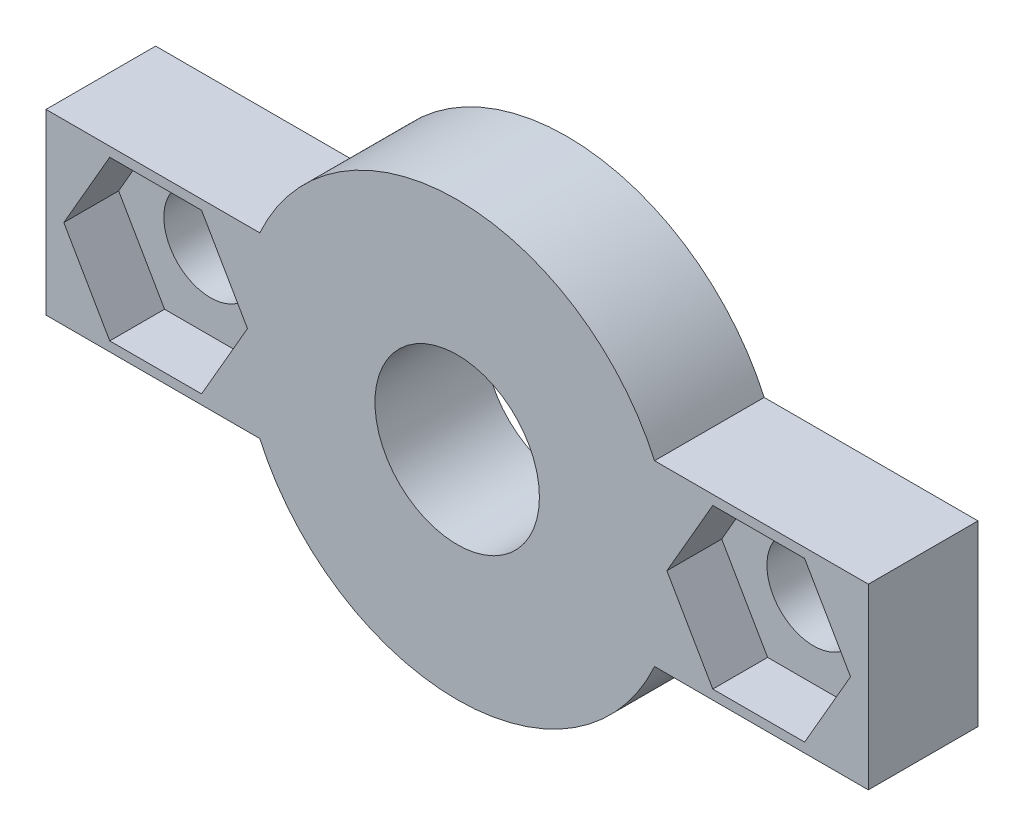
from build123d import *

# Parameters (mm, degrees)
CROQUIS1_R              = 3
SALIENTE_EXTRUIR1_DEPTH = 4
CORTAR_EXTRUIR1_DEPTH   = 2
CROQUIS3_R              = 1.7
CORTAR_EXTRUIR2_DEPTH   = 10


with BuildPart() as part:
    # Croquis1 → Saliente-Extruir1 (new body)
    with BuildSketch(Plane.XY):
        with BuildLine():
            Line((-7.200520814, 3.25), (-15, 3.25))
            Line((-15, 3.25), (-15, -3.25))
            Line((-15, -3.25), (-7.200520814, -3.25))
            ThreePointArc((-7.200520814, -3.25), (0, -7.9), (7.200520814, -3.25))
            Line((7.200520814, -3.25), (15, -3.25))
            Line((15, -3.25), (15, 3.25))
            Line((15, 3.25), (7.200520814, 3.25))
            ThreePointArc((7.200520814, 3.25), (0, 7.9), (-7.200520814, 3.25))
        make_face()
        Circle(CROQUIS1_R, mode=Mode.SUBTRACT)
    extrude(amount=SALIENTE_EXTRUIR1_DEPTH)

    # Croquis2 → Cortar-Extruir1 (cut)
    with BuildSketch(Plane.XY.offset(4)):
        Polygon((-14.35, 0), (-12.675, -2.901185103), (-9.325, -2.901185103), (-7.65, 0), (-9.325, 2.901185103), (-12.675, 2.901185103), align=None)
        Polygon((14.35, 0), (12.675, 2.901185103), (9.325, 2.901185103), (7.65, 0), (9.325, -2.901185103), (12.675, -2.901185103), align=None)
    extrude(amount=-CORTAR_EXTRUIR1_DEPTH, mode=Mode.SUBTRACT)

    # Croquis3 → Cortar-Extruir2 (cut)
    with BuildSketch(Plane.XY.offset(4)):
        with Locations((-11, 0)):
            Circle(CROQUIS3_R)
        with Locations((11, 0)):
            Circle(CROQUIS3_R)
    extrude(amount=-CORTAR_EXTRUIR2_DEPTH, mode=Mode.SUBTRACT)


solid = part.part
